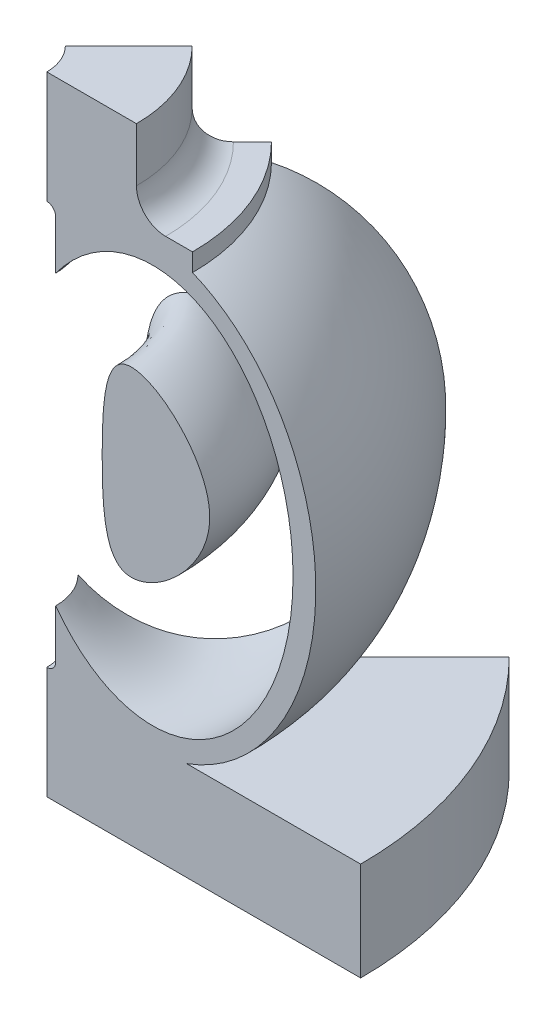
from build123d import *

# Parameters (mm, degrees)
REVOLU_O2_ANGLE = 45
ESBO_O3_RX      = 22243.320272913
ESBO_O3_RY      = 15640.553132373
REVOLU_O3_ANGLE = 45


with BuildPart() as part:
    # Esboço2 → Revolução2 (revolve)
    with BuildSketch(Plane.XY):
        with BuildLine():
            Line((5000, 70000), (5000, 57500))
            ThreePointArc((5000, 57500), (5707.106781187, 57207.106781187), (6000, 56500))
            Line((6000, 56500), (6000, 13500))
            ThreePointArc((6000, 13500), (5707.106781187, 12792.893218813), (5000, 12500))
            Line((5000, 12500), (5000, 0))
            Line((5000, 0), (40000, 0))
            Line((40000, 0), (40000, 11000))
            Line((40000, 11000), (20600, 11000))
            add(Edge.make_bspline(
                [(20600, 11000), (82470.907399998, 33557.10165625), (21253.492737805, 58746.507262195)],
                knots=[3.425386763, 3.425386763, 3.425386763, 5.965177753, 5.965177753, 5.965177753], degree=2, weights=[1, 0.296380684, 1]))
            Line((21253.492737805, 58746.507262195), (21253.492737805, 60746.507262195))
            Line((21253.492737805, 60746.507262195), (18253.492737805, 60746.507262195))
            ThreePointArc((18253.492737805, 60746.507262195), (15952.925960362, 61699.433222557), (15000, 64000))
            Line((15000, 64000), (15000, 70000))
            Line((15000, 70000), (5000, 70000))
        make_face()
    revolve(axis=Axis((0, 0, 0), (0, 1, 0)), revolution_arc=REVOLU_O2_ANGLE)

    # Esboço3 → Corte-Revolução1 (revolve, cut)
    with BuildSketch(Plane.XY):
        with Locations(Location((16820.62504111, 35000), (0, 0, -90))):
            Ellipse(ESBO_O3_RX, ESBO_O3_RY)
    revolve(axis=Axis((0, 0, 0), (0, 1, 0)), mode=Mode.SUBTRACT)


with BuildPart() as body_2:
    # Esboço4 → Revolução3 (revolve)
    with BuildSketch(Plane.XY):
        with BuildLine():
            add(Edge.make_bspline(
                [(11179.900249992, 36060.085021), (11179.900249992, 40628.19603411), (11598.590022909, 51362.209201007), (29822.454563098, 36060.085021), (11598.590022909, 20757.960840993), (11179.900249992, 31491.97400789), (11179.900249992, 36060.085021)],
                knots=[0, 0, 0, 0, 0.212786725, 0.5, 0.787213275, 1, 1, 1, 1], degree=3))
        make_face()
    revolve(axis=Axis((0, 0, 0), (0, 1, 0)), revolution_arc=REVOLU_O3_ANGLE)


solid = Compound([part.part, body_2.part])
